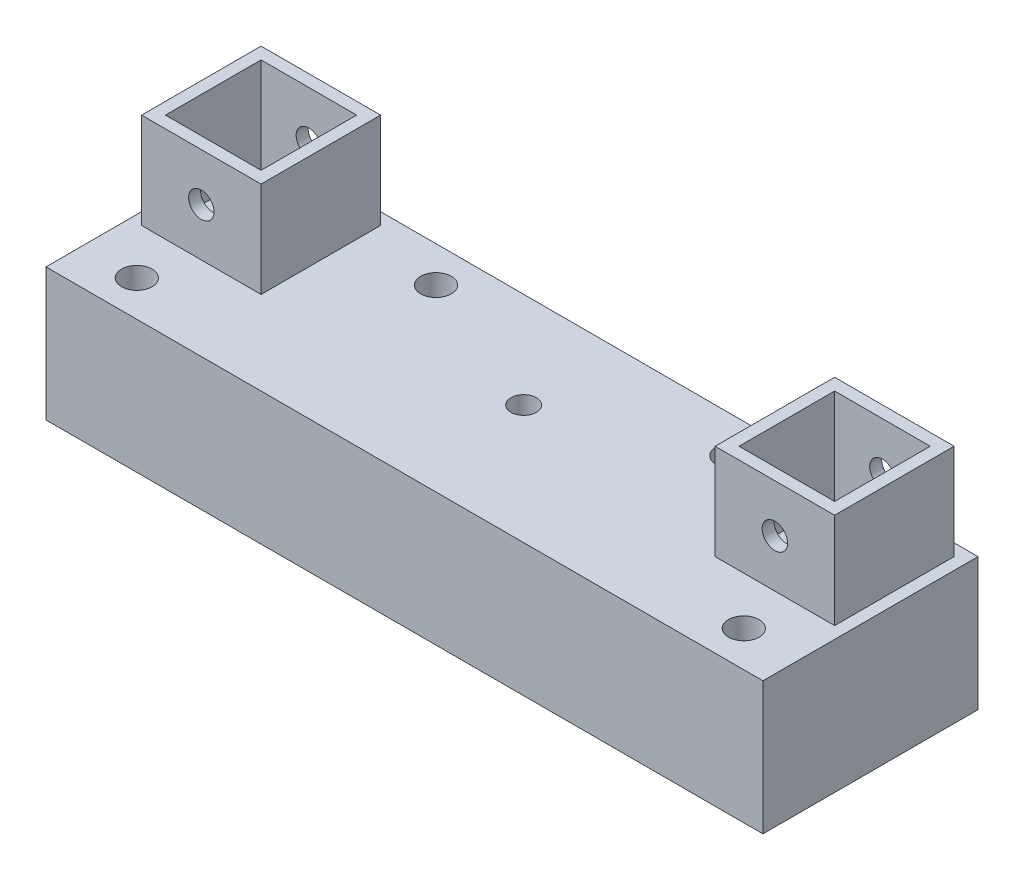
from build123d import *

# Parameters (mm, degrees)
SKETCH1_W           = 190.5
SKETCH1_H           = 57.15
BOSS_EXTRUDE1_DEPTH = 35.2298
SKETCH2_R           = 3.3782
CUT_EXTRUDE1_DEPTH  = 35.2298
SKETCH3_W           = 31.75
SKETCH3_H           = 31.75
SKETCH3_W_2         = 25.4
SKETCH3_H_2         = 25.4
BOSS_EXTRUDE2_DEPTH = 25.4
SKETCH4_R           = 3.3782
CUT_EXTRUDE2_DEPTH  = 54.975
SKETCH5_R           = 2.54
CUT_EXTRUDE3_DEPTH  = 35.2298
SKETCH6_R           = 4.064
CUT_EXTRUDE4_DEPTH  = 28.8798
CUT_EXTRUDE5_DEPTH  = 9.8298


with BuildPart() as part:
    # Sketch1 → Boss-Extrude1 (new body)
    with BuildSketch(Plane(origin=(0, 0, 0), x_dir=(1, 0, 0), z_dir=(0, 1, 0))):
        Rectangle(SKETCH1_W, SKETCH1_H)
    extrude(amount=BOSS_EXTRUDE1_DEPTH)

    # Sketch2 → Cut-Extrude1 (cut)
    with BuildSketch(Plane(origin=(0, 35.2298, 0), x_dir=(1, 0, 0), z_dir=(0, 1, 0))):
        with Locations((0, 3.0988)):
            Circle(SKETCH2_R)
    extrude(amount=-CUT_EXTRUDE1_DEPTH, mode=Mode.SUBTRACT)

    # Sketch3 → Boss-Extrude2 (add)
    with BuildSketch(Plane(origin=(0, 35.2298, 0), x_dir=(1, 0, 0), z_dir=(0, 1, 0))):
        with Locations((76.2, 9.525)):
            Rectangle(SKETCH3_W, SKETCH3_H)
        with Locations((76.2, 9.525)):
            Rectangle(SKETCH3_W_2, SKETCH3_H_2, mode=Mode.SUBTRACT)
    boss_extrude2 = extrude(amount=BOSS_EXTRUDE2_DEPTH)

    # Sketch4 → Cut-Extrude2 (cut, through all)
    with BuildSketch(Plane(origin=(0, 0, -25.4), x_dir=(-1, 0, 0), z_dir=(0, 0, -1))):
        with Locations((-76.2, 47.9298)):
            Circle(SKETCH4_R)
    cut_extrude2 = extrude(amount=-CUT_EXTRUDE2_DEPTH, mode=Mode.SUBTRACT)

    # Sketch5 → Cut-Extrude3 (cut)
    with BuildSketch(Plane.XZ):
        with Locations((80.645, 19.05)):
            Circle(SKETCH5_R)
        with Locations((39.243, -19.05)):
            Circle(SKETCH5_R)
    cut_extrude3 = extrude(amount=-CUT_EXTRUDE3_DEPTH, mode=Mode.SUBTRACT)

    # Sketch6 → Cut-Extrude4 (cut)
    with BuildSketch(Plane(origin=(0, 35.2298, 0), x_dir=(1, 0, 0), z_dir=(0, 1, 0))):
        with Locations((80.645, -19.05)):
            Circle(SKETCH6_R)
        with Locations((39.243, 19.05)):
            Circle(SKETCH6_R)
    cut_extrude4 = extrude(amount=-CUT_EXTRUDE4_DEPTH, mode=Mode.SUBTRACT)

    # Mirror1: Boss-Extrude2, Cut-Extrude2, Cut-Extrude3, Cut-Extrude4 across plane
    add(boss_extrude2.mirror(Plane(origin=(0, 0, 0), x_dir=(0, 0, 1), z_dir=(1, 0, 0))))
    add(cut_extrude2.mirror(Plane(origin=(0, 0, 0), x_dir=(0, 0, 1), z_dir=(1, 0, 0))), mode=Mode.SUBTRACT)
    add(cut_extrude3.mirror(Plane(origin=(0, 0, 0), x_dir=(0, 0, 1), z_dir=(1, 0, 0))), mode=Mode.SUBTRACT)
    add(cut_extrude4.mirror(Plane(origin=(0, 0, 0), x_dir=(0, 0, 1), z_dir=(1, 0, 0))), mode=Mode.SUBTRACT)

    # Sketch7 → Cut-Extrude5 (cut)
    with BuildSketch(Plane.XZ):
        Polygon((6.599113577, -3.0988), (3.299556788, 2.6162), (-3.299556788, 2.6162), (-6.599113577, -3.0988), (-3.299556788, -8.8138), (3.299556788, -8.8138), align=None)
    extrude(amount=-CUT_EXTRUDE5_DEPTH, mode=Mode.SUBTRACT)


solid = part.part
